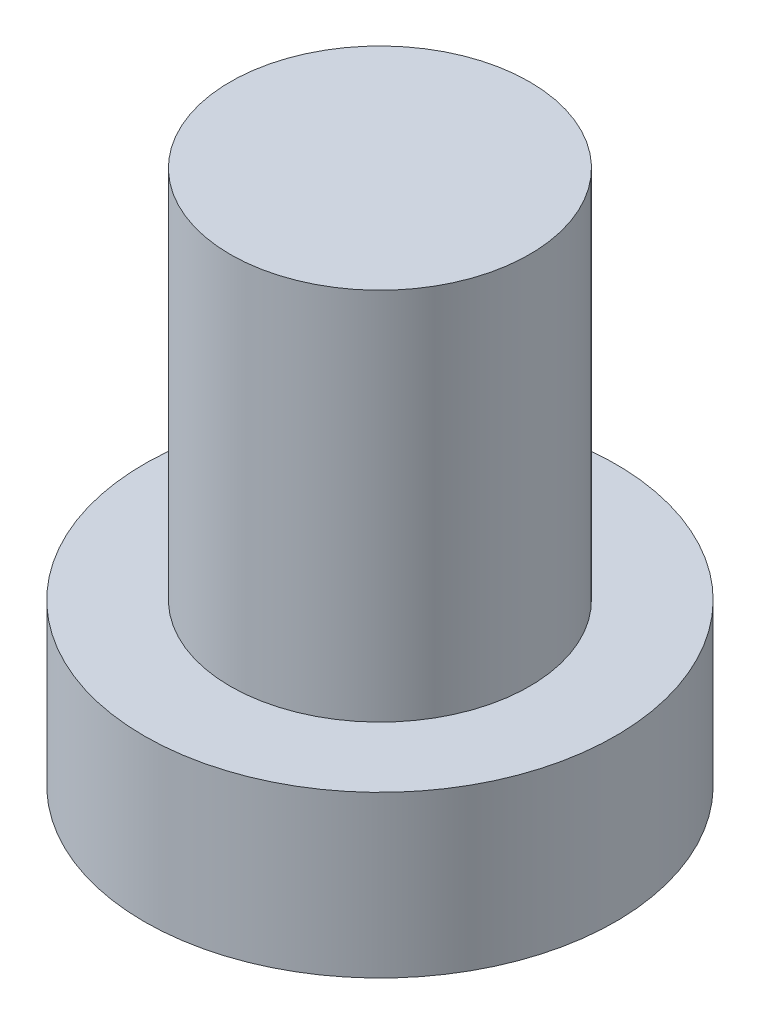
from build123d import *

# Parameters (mm, degrees)
SKETCH_1_R          = 3.15
EXTRUDE_1_DEPTH     = 2.15
SKETCH_2_R          = 2
EXTRUDE_2_DEPTH     = 5
CUT_EXTRUDE_1_DEPTH = 1.5


with BuildPart() as part:
    # 草图1 → 凸台-拉伸1 (new body)
    with BuildSketch(Plane(origin=(0, 0, 0), x_dir=(1, 0, 0), z_dir=(0, 1, 0))):
        Circle(SKETCH_1_R)
    extrude(amount=EXTRUDE_1_DEPTH)

    # 草图2 → 凸台-拉伸2 (add)
    with BuildSketch(Plane(origin=(0, 2.15, 0), x_dir=(1, 0, 0), z_dir=(0, 1, 0))):
        Circle(SKETCH_2_R)
    extrude(amount=EXTRUDE_2_DEPTH)

    # 草图3 → 切除-拉伸1 (cut)
    with BuildSketch(Plane.XZ):
        with BuildLine():
            Line((-0.5, 1), (-0.5, 2))
            Line((-0.5, 2), (0.5, 2))
            Line((0.5, 2), (0.5, 1))
            ThreePointArc((0.5, 1), (0.646446609, 0.646446609), (1, 0.5))
            Line((1, 0.5), (2, 0.5))
            Line((2, 0.5), (2, -0.5))
            Line((2, -0.5), (1, -0.5))
            ThreePointArc((1, -0.5), (0.646446609, -0.646446609), (0.5, -1))
            Line((0.5, -1), (0.5, -2))
            Line((0.5, -2), (-0.5, -2))
            Line((-0.5, -2), (-0.5, -1))
            ThreePointArc((-0.5, -1), (-0.646446609, -0.646446609), (-1, -0.5))
            Line((-1, -0.5), (-2, -0.5))
            Line((-2, -0.5), (-2, 0.5))
            Line((-2, 0.5), (-1, 0.5))
            ThreePointArc((-1, 0.5), (-0.646446609, 0.646446609), (-0.5, 1))
        make_face()
    extrude(amount=-CUT_EXTRUDE_1_DEPTH, mode=Mode.SUBTRACT)


solid = part.part
